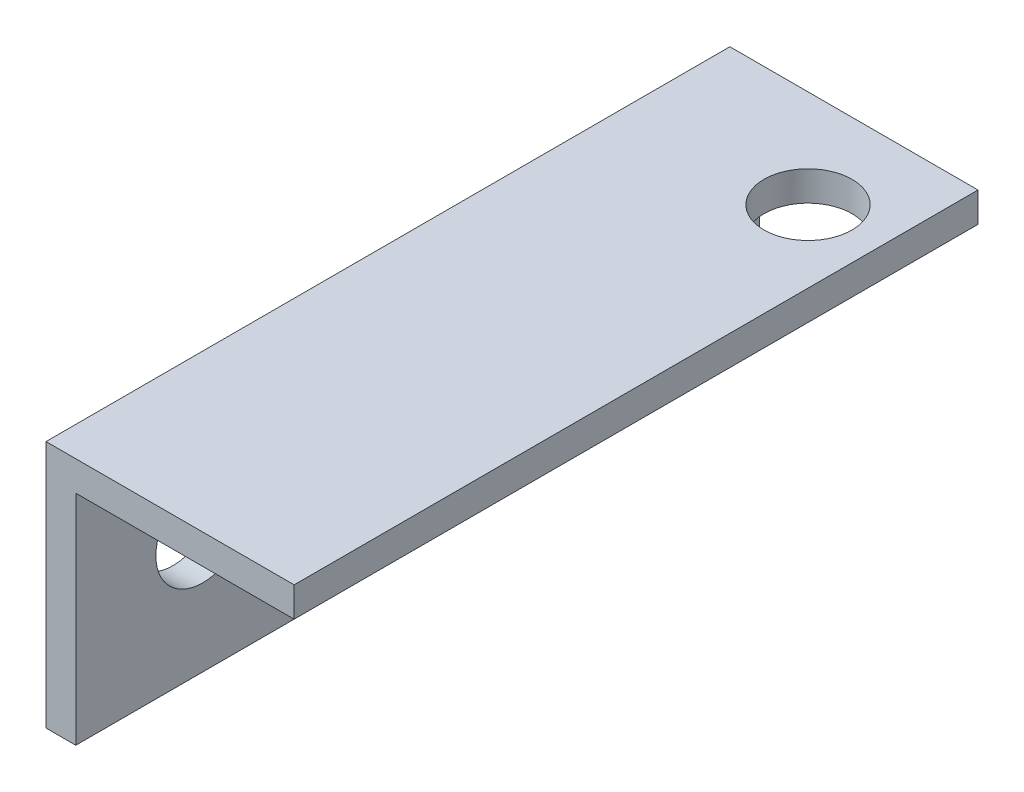
from build123d import *

# Parameters (mm, degrees)
BOSS_EXTRUDE1_DEPTH  = 35
M4_CLEARANCE_HOLE1_D = 4.5
M4_CLEARANCE_HOLE2_D = 4.8


with BuildPart() as part:
    # Sketch1 → Boss-Extrude1 (new body)
    with BuildSketch(Plane.XY):
        Polygon((0, 0), (12.7, 0), (12.7, -1.524), (1.524, -1.524), (1.524, -12.7), (0, -12.7), align=None)
    extrude(amount=BOSS_EXTRUDE1_DEPTH)

    # M4 Clearance Hole1 (through all)
    with Locations(Plane(origin=(0, 0, 0), x_dir=(1, 0, 0), z_dir=(0, 1, 0))):
        with Locations((9, -5)):
            Hole(M4_CLEARANCE_HOLE1_D / 2)

    # M4 Clearance Hole2 (through all)
    with Locations(Plane.ZY):
        with Locations((15, -6.35), (28.5, -6.35)):
            Hole(M4_CLEARANCE_HOLE2_D / 2)


solid = part.part
